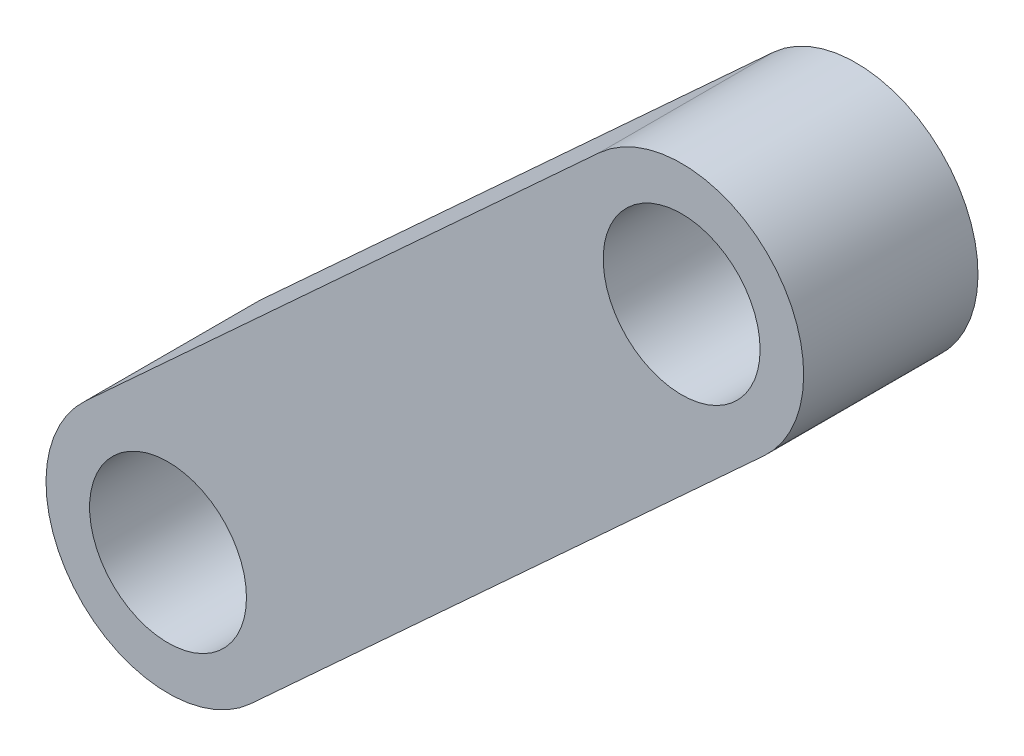
from build123d import *

# Parameters (mm, degrees)
SKETCH1_R           = 45
BOSS_EXTRUDE1_DEPTH = 100


with BuildPart() as part:
    # Sketch1 → Boss-Extrude1 (new body)
    with BuildSketch(Plane.XY):
        with BuildLine():
            Line((-47.347064855, 51.558272368), (247.271634392, 322.112928684))
            ThreePointArc((247.271634392, 322.112928684), (346.176971615, 317.901721171), (341.965764102, 218.996383947))
            Line((341.965764102, 218.996383947), (47.347064855, -51.558272368))
            ThreePointArc((47.347064855, -51.558272368), (-51.558272368, -47.347064855), (-47.347064855, 51.558272368))
        make_face()
        Circle(SKETCH1_R, mode=Mode.SUBTRACT)
        with Locations((294.618699247, 270.554656316)):
            Circle(SKETCH1_R, mode=Mode.SUBTRACT)
    extrude(amount=BOSS_EXTRUDE1_DEPTH)


solid = part.part
